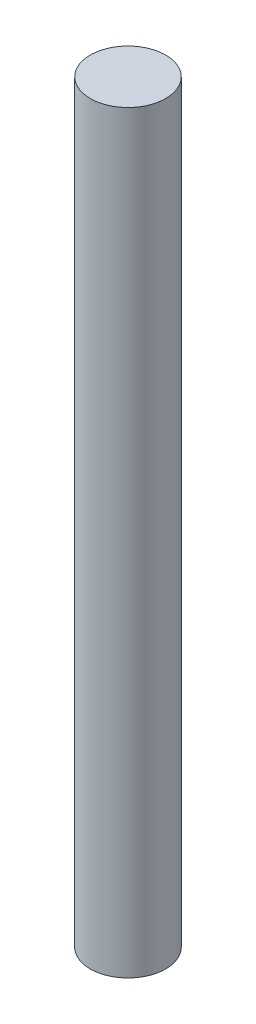
from build123d import *

# Parameters (mm, degrees)
SKETCH1_R           = 25
BOSS_EXTRUDE1_DEPTH = 500


with BuildPart() as part:
    # Sketch1 → Boss-Extrude1 (new body)
    with BuildSketch(Plane(origin=(0, 0, 0), x_dir=(1, 0, 0), z_dir=(0, 1, 0))):
        Circle(SKETCH1_R)
    extrude(amount=BOSS_EXTRUDE1_DEPTH)


solid = part.part
